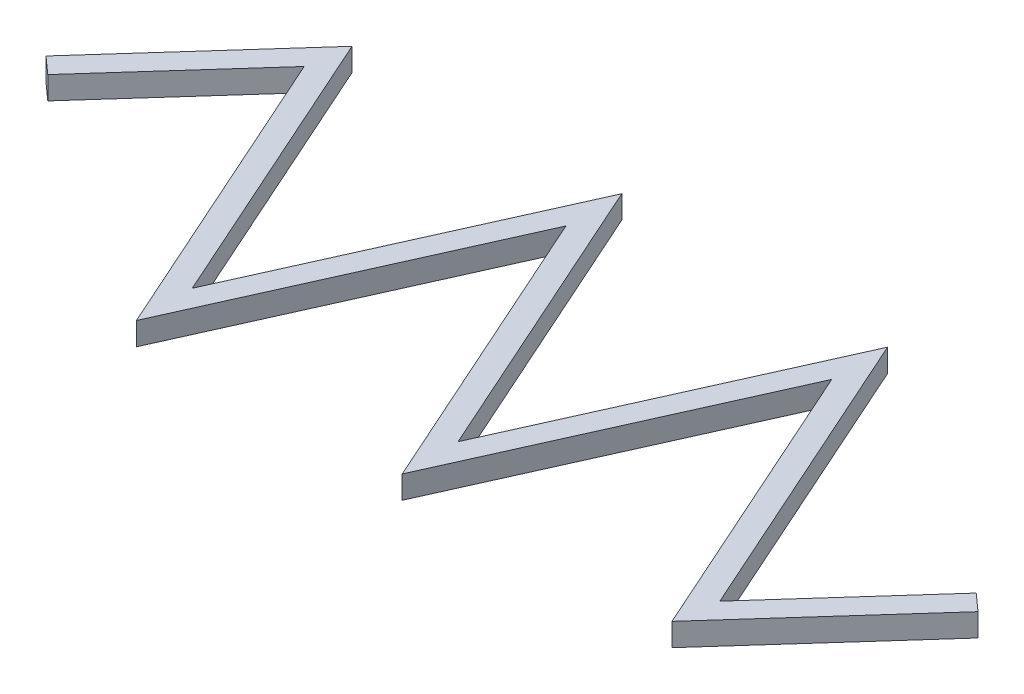
from build123d import *

# Parameters (mm, degrees)
BOSS_EXTRUDE1_DEPTH = 2


with BuildPart() as part:
    # Sketch1 → Boss-Extrude1 (new body)
    with BuildSketch(Plane(origin=(0, 0, 0), x_dir=(1, 0, 0), z_dir=(0, 1, 0))):
        Polygon((-93.922283941, 0.667291311), (-93.177487119, 0), (-81.530301229, 13), (-69.883115339, -13), (-58.235929449, 13), (-46.588743559, -13), (-34.941557669, 13), (-23.29437178, -13), (-11.64718589, 0), (-12.391982712, 0.667291311), (-23.011418731, -11.185586247), (-34.941557669, 15.446049526), (-46.588743559, -10.553950474), (-58.235929449, 15.446049526), (-69.883115339, -10.553950474), (-81.24734818, 14.814413753), align=None)
        Polygon((-81.530301229, 13), (-93.177487119, 0), (-92.432690296, -0.667291311), (-81.813254277, 11.185586247), (-69.883115339, -15.446049526), (-58.235929449, 10.553950474), (-46.588743559, -15.446049526), (-34.941557669, 10.553950474), (-23.577324828, -14.814413753), (-10.902389067, -0.667291311), (-11.64718589, 0), (-23.29437178, -13), (-34.941557669, 13), (-46.588743559, -13), (-58.235929449, 13), (-69.883115339, -13), align=None)
    extrude(amount=BOSS_EXTRUDE1_DEPTH)


solid = part.part
